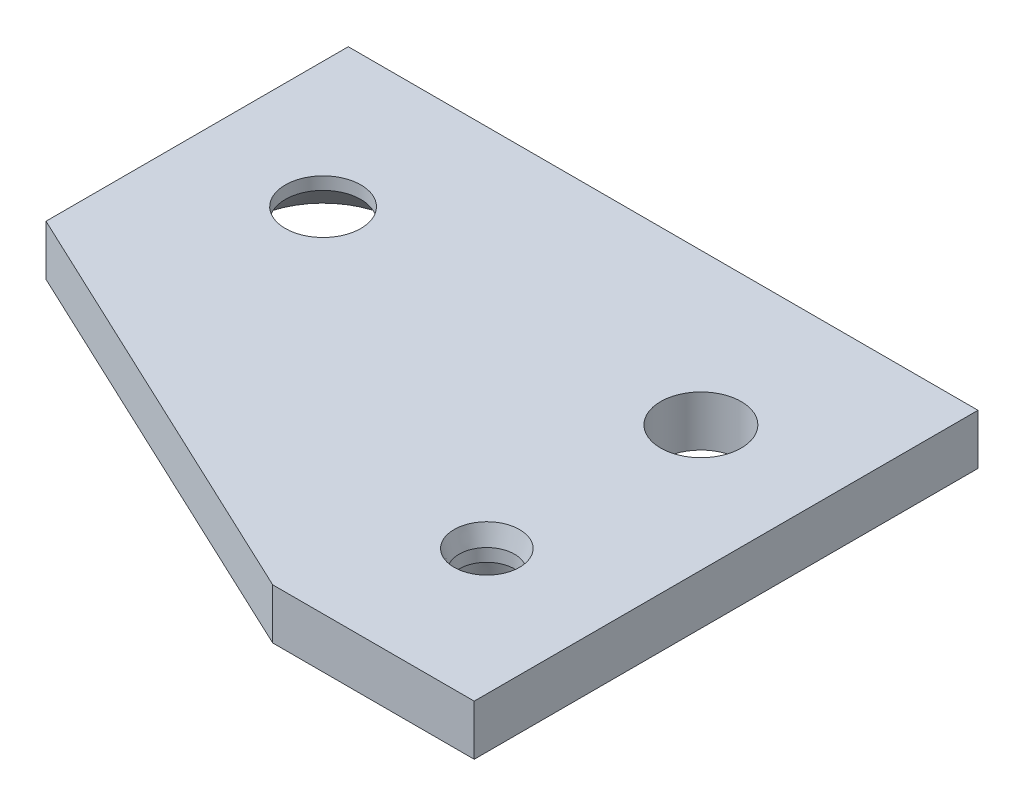
from build123d import *

# Parameters (mm, degrees)
SKETCH1_R             = 1.6
SKETCH1_R_2           = 1.5
SKETCH1_R_3           = 1.1
EXTRUDE1_DEPTH        = 2
CHAMFER1_SIZE         = 1.5
CHAMFER2_SIZE         = 0.2
CHAMFER2_SIZE2        = 0.746410162
CHAMFER2_PART_2_SIZE  = 0.2
CHAMFER2_PART_2_SIZE2 = 0.746410162


with BuildPart() as part:
    # Sketch1 → Extrude1 (new body)
    with BuildSketch(Plane(origin=(0, 0, 0), x_dir=(1, 0, 0), z_dir=(0, 1, 0))):
        Polygon((-20, 6), (5, 6), (5, -14), (-3, -14), (-20, -6), align=None)
        with Locations(Location((0, 0, 0), (0, 0, 270))):  # turned: the seam where the file's is
            Circle(SKETCH1_R, mode=Mode.SUBTRACT)
        with Locations(Location((-15, 0, 0), (0, 0, 270))):  # turned: the seam where the file's is
            Circle(SKETCH1_R_2, mode=Mode.SUBTRACT)
        with Locations(Location((0, -8.5, 0), (0, 0, 270))):  # turned: the seam where the file's is
            Circle(SKETCH1_R_3, mode=Mode.SUBTRACT)
    extrude(amount=EXTRUDE1_DEPTH)

    # Chamfer1
    chamfer1_edges = [part.edges().sort_by_distance(p)[0] for p in [
        (-15, 0, -1.5),
    ]]
    chamfer(chamfer1_edges, length=CHAMFER1_SIZE)

    # Chamfer2
    chamfer2_edges = [part.edges().sort_by_distance(p)[0] for p in [
        (0, 0, 7.4),
    ]]
    chamfer2_side = [part.faces().sort_by_distance(p)[0] for p in [
        (-5.999814113, 0, 3.054548244),
    ]]
    chamfer(chamfer2_edges, length=CHAMFER2_SIZE, length2=CHAMFER2_SIZE2, reference=chamfer2_side[0])

    # Chamfer2 part 2
    chamfer2_part_2_edges = [part.edges().sort_by_distance(p)[0] for p in [
        (0, 2, 7.4),
    ]]
    chamfer2_part_2_side = [part.faces().sort_by_distance(p)[0] for p in [
        (-6.46183643, 2, 2.897743765),
    ]]
    chamfer(chamfer2_part_2_edges, length=CHAMFER2_PART_2_SIZE, length2=CHAMFER2_PART_2_SIZE2, reference=chamfer2_part_2_side[0])


solid = part.part
